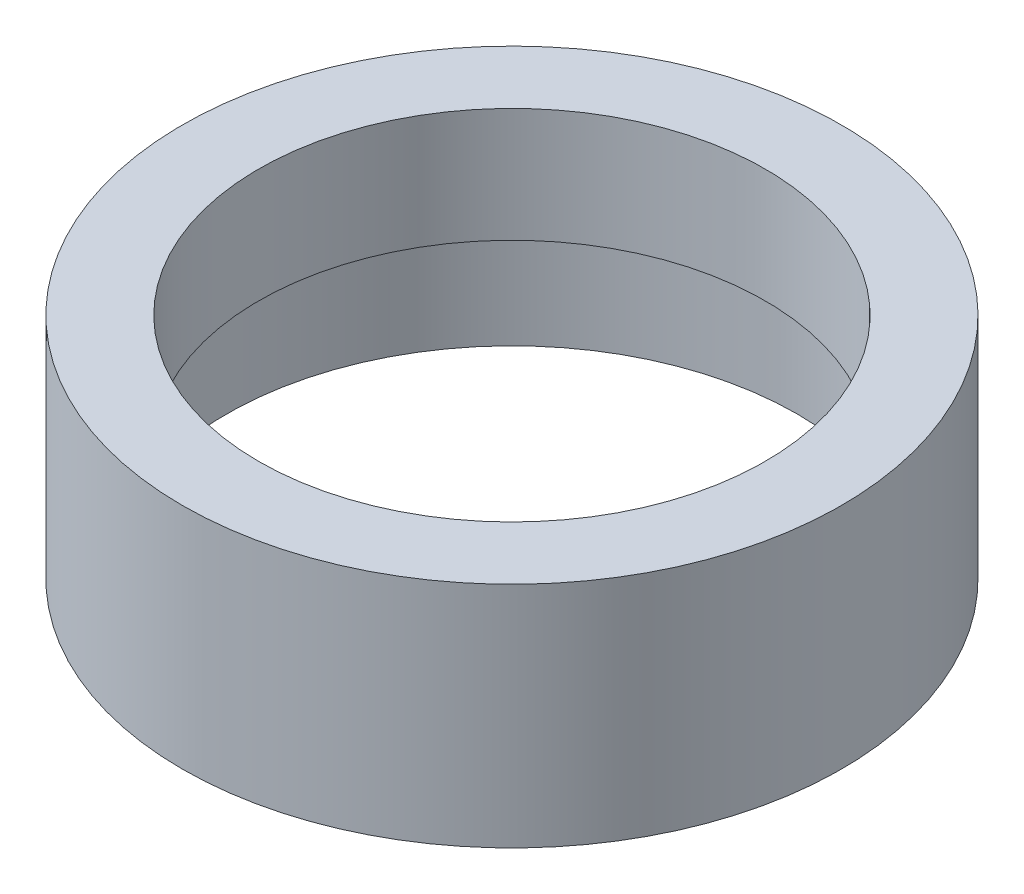
from build123d import *


with BuildPart() as part:
    # 草图1 → 旋转1 (revolve)
    with BuildSketch(Plane.XY, mode=Mode.PRIVATE) as revolve_1_sk:
        Polygon((13.75, 0), (13.75, 4.5), (14.35, 4.5), (14.35, 5.5), (12.2, 5.5), (12.2, 11), (15.875, 11), (15.875, 0), align=None)
    revolve(revolve_1_sk.sketch.rotate(Axis((0, 60.020820414, 0), (0, -1, 0)), 90), axis=Axis((0, 60.020820414, 0), (0, -1, 0)))  # turned: the seam where the file's is


solid = part.part
